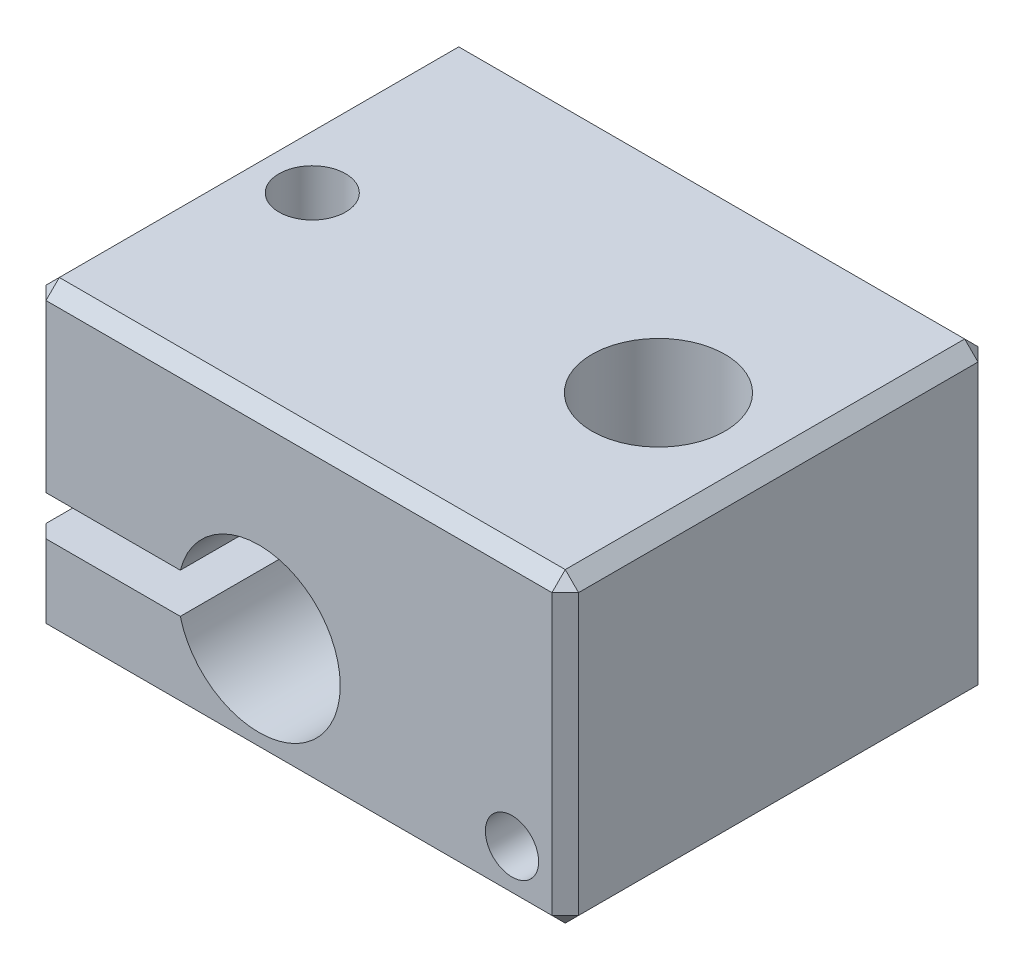
from build123d import *

# Parameters (mm, degrees)
SKETCH1_W             = 20
SKETCH1_H             = 16
BOSS_EXTRUDE1_DEPTH   = 11.5
M3X0_5_TAPPED_HOLE1_D = 2.5
M6_TAPPED_HOLE1_D     = 5
CUT_EXTRUDE1_DEPTH    = 16
SKETCH10_R            = 1
CUT_EXTRUDE2_DEPTH    = 2
SKETCH11_R            = 0.75
CUT_EXTRUDE3_DEPTH    = 2.5
CHAMFER1_SIZE         = 0.5


with BuildPart() as part:
    # Sketch1 → Boss-Extrude1 (new body)
    with BuildSketch(Plane(origin=(0, 0, 0), x_dir=(1, 0, 0), z_dir=(0, 1, 0))):
        with Locations((10, 8)):
            Rectangle(SKETCH1_W, SKETCH1_H)
    extrude(amount=BOSS_EXTRUDE1_DEPTH)

    # M3x0.5 Tapped Hole1 (through all)
    with Locations(Plane(origin=(0, 11.5, 0), x_dir=(1, 0, 0), z_dir=(0, 1, 0))):
        with Locations((2.5, 8)):
            Hole(M3X0_5_TAPPED_HOLE1_D / 2)

    # M6 Tapped Hole1 (through all)
    with Locations(Plane(origin=(0, 11.5, 0), x_dir=(1, 0, 0), z_dir=(0, 1, 0))):
        with Locations((15.5, 8)):
            Hole(M6_TAPPED_HOLE1_D / 2)

    # Sketch2 → Cut-Extrude1 (cut)
    with BuildSketch(Plane.XY):
        with BuildLine():
            Line((5.5436509, 4.75), (0, 4.75))
            Line((0, 4.75), (0, 3.25))
            Line((0, 3.25), (5.5436509, 3.25))
            ThreePointArc((5.5436509, 3.25), (5.45, 4), (5.5436509, 4.75))
        make_face()
        with BuildLine():
            ThreePointArc((11.55, 4), (8.877912189, 7.026496717), (5.5436509, 4.75))
            Line((5.5436509, 4.75), (5.5436509, 3.25))
            ThreePointArc((5.5436509, 3.25), (8.877912189, 0.973503283), (11.55, 4))
        make_face()
        with BuildLine():
            Line((5.5436509, 3.25), (5.5436509, 4.75))
            ThreePointArc((5.5436509, 4.75), (5.45, 4), (5.5436509, 3.25))
        make_face()
    extrude(amount=-CUT_EXTRUDE1_DEPTH, mode=Mode.SUBTRACT)

    # Sketch10 → Cut-Extrude2 (cut)
    with BuildSketch(Plane.XY):
        with Locations((18, 2)):
            Circle(SKETCH10_R)
    extrude(amount=-CUT_EXTRUDE2_DEPTH, mode=Mode.SUBTRACT)

    # Sketch11 → Cut-Extrude3 (cut)
    with BuildSketch(Plane.XY.offset(-2)):
        with Locations((18, 2)):
            Circle(SKETCH11_R)
    extrude(amount=-CUT_EXTRUDE3_DEPTH, mode=Mode.SUBTRACT)

    # Chamfer1
    chamfer1_edges = [part.edges().sort_by_distance(p)[0] for p in [
        (20, 11.5, -8),
        (10, 11.5, -16),
        (0, 1.625, -16),
        (0, 1.625, 0),
        (0, 11.5, -8),
        (10, 0, -16),
        (20, 0, -8),
        (10, 0, 0),
        (0, 0, -8),
        (10, 11.5, 0),
        (0, 8.125, -16),
        (20, 5.75, -16),
        (20, 5.75, 0),
        (0, 8.125, 0),
    ]]
    chamfer(chamfer1_edges, length=CHAMFER1_SIZE)


solid = part.part
